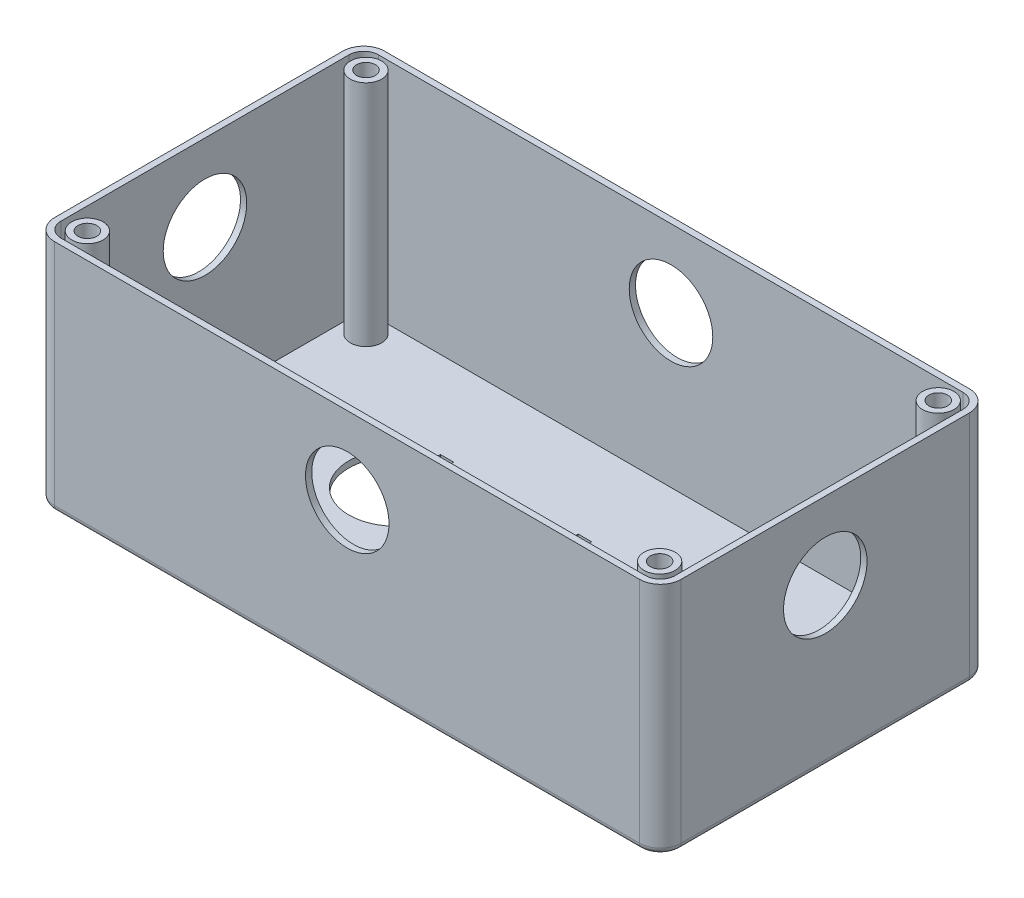
from build123d import *

# Parameters (mm, degrees)
SKETCH1_R           = 2.25
BOSS_EXTRUDE1_DEPTH = 56.2
SHELL1_T            = -1.5
SKETCH2_W           = 107.526504688
SKETCH2_H           = 43.658783516
CUT_EXTRUDE1_DEPTH  = 54.7
FILLET1_R           = 1.5
SKETCH3_R           = 10
CUT_EXTRUDE2_DEPTH  = 123.692467131
SKETCH4_R           = 10
CUT_EXTRUDE3_DEPTH  = 167.248879786
SKETCH6_W           = 22.5
SKETCH6_H           = 15
CUT_EXTRUDE5_DEPTH  = 0.25


with BuildPart() as part:
    # Sketch1 → Boss-Extrude1 (new body)
    with BuildSketch(Plane(origin=(0, 0, 0), x_dir=(1, 0, 0), z_dir=(0, 1, 0))):
        with BuildLine():
            Line((-70.193094701, 34.5), (69.806905299, 34.5))
            ThreePointArc((69.806905299, 34.5), (73.342439205, 33.035533906), (74.806905299, 29.5))
            Line((74.806905299, 29.5), (74.806905299, -39.5))
            ThreePointArc((74.806905299, -39.5), (73.342439205, -43.035533906), (69.806905299, -44.5))
            Line((69.806905299, -44.5), (-70.193094701, -44.5))
            ThreePointArc((-70.193094701, -44.5), (-73.728628607, -43.035533906), (-75.193094701, -39.5))
            Line((-75.193094701, -39.5), (-75.193094701, 29.5))
            ThreePointArc((-75.193094701, 29.5), (-73.728628607, 33.035533906), (-70.193094701, 34.5))
        make_face()
        with Locations(Location((68.5, 28.35, 0), (0, 0, 270))):
            Circle(SKETCH1_R, mode=Mode.SUBTRACT)
        with Locations(Location((68.5, -38.35, 0), (0, 0, 270))):
            Circle(SKETCH1_R, mode=Mode.SUBTRACT)
        with Locations(Location((-68.5, -38.35, 0), (0, 0, 90))):
            Circle(SKETCH1_R, mode=Mode.SUBTRACT)
        with Locations(Location((-68.5, 28.35, 0), (0, 0, 90))):
            Circle(SKETCH1_R, mode=Mode.SUBTRACT)
        with BuildLine():
            Line((-34.6, 11.135640978), (-34.6, 12.25))
            Line((-34.6, 12.25), (-31.4, 12.25))
            Line((-31.4, 12.25), (-31.4, 11.135640978))
            ThreePointArc((-31.4, 11.135640978), (-33, -11.25), (-34.6, 11.135640978))
        make_face(mode=Mode.SUBTRACT)
        with BuildLine():
            Line((-1.6, 11.135640978), (-1.6, 12.25))
            Line((-1.6, 12.25), (1.6, 12.25))
            Line((1.6, 12.25), (1.6, 11.135640978))
            ThreePointArc((1.6, 11.135640978), (0, -11.25), (-1.6, 11.135640978))
        make_face(mode=Mode.SUBTRACT)
        with BuildLine():
            Line((38.4, 11.135640978), (38.4, 12.25))
            Line((38.4, 12.25), (41.6, 12.25))
            Line((41.6, 12.25), (41.6, 11.135640978))
            ThreePointArc((41.6, 11.135640978), (40, -11.25), (38.4, 11.135640978))
        make_face(mode=Mode.SUBTRACT)
    extrude(amount=BOSS_EXTRUDE1_DEPTH)

    # Shell1
    shell1_openings = [part.faces().sort_by_distance(p)[0] for p in [
        (-0.193094701, 56.2, -32.804682921),
    ]]
    offset(amount=SHELL1_T, openings=shell1_openings, kind=Kind.INTERSECTION)

    # Sketch2 → Cut-Extrude1 (cut)
    with BuildSketch(Plane(origin=(0, 56.2, 0), x_dir=(1, 0, 0), z_dir=(0, 1, 0))):
        Rectangle(SKETCH2_W, SKETCH2_H)
    extrude(amount=-CUT_EXTRUDE1_DEPTH, mode=Mode.SUBTRACT)

    # Fillet1
    fillet1_edges = [part.edges().sort_by_distance(p)[0] for p in [
        (-75.193094701, 0, 5),
        (-73.728628607, 0, -33.035533906),
        (-0.193094701, 0, -34.5),
        (73.342439205, 0, -33.035533906),
        (74.806905299, 0, 5),
        (73.342439205, 0, 43.035533906),
        (-0.193094701, 0, 44.5),
        (-73.728628607, 0, 43.035533906),
    ]]
    fillet(fillet1_edges, radius=FILLET1_R)

    # Sketch3 → Cut-Extrude2 (cut, through all)
    with BuildSketch(Plane(origin=(0, 0, -34.5), x_dir=(-1, 0, 0), z_dir=(0, 0, -1))):
        with Locations((0.129531499, 37.7)):
            Circle(SKETCH3_R)
    extrude(amount=-CUT_EXTRUDE2_DEPTH, mode=Mode.SUBTRACT)

    # Sketch4 → Cut-Extrude3 (cut, through all)
    with BuildSketch(Plane.ZY.offset(75.193094701)):
        with Locations((5, 37.7)):
            Circle(SKETCH4_R)
    extrude(amount=-CUT_EXTRUDE3_DEPTH, mode=Mode.SUBTRACT)

    # Sketch6 → Cut-Extrude5 (cut)
    with BuildSketch(Plane.XZ):
        with Locations((-33, 30.85)):
            Rectangle(SKETCH6_W, SKETCH6_H)
        with Locations((40, 30.85)):
            Rectangle(SKETCH6_W, SKETCH6_H)
        with Locations((0, 30.85)):
            Rectangle(SKETCH6_W, SKETCH6_H)
    extrude(amount=-CUT_EXTRUDE5_DEPTH, mode=Mode.SUBTRACT)


solid = part.part
